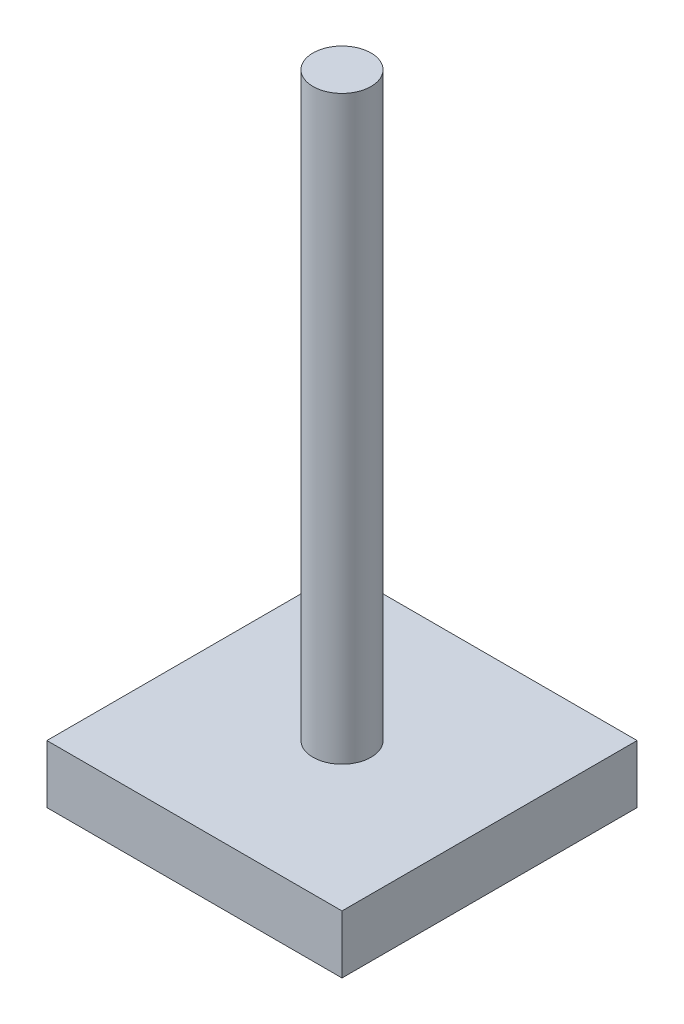
from build123d import *

# Parameters (mm, degrees)
SKETCH2_W           = 50.8
SKETCH2_H           = 50.8
BOSS_EXTRUDE1_DEPTH = 10
SKETCH3_R           = 5
BOSS_EXTRUDE3_DEPTH = 100


with BuildPart() as part:
    # Sketch2 → Boss-Extrude1 (new body)
    with BuildSketch(Plane(origin=(0, 0, 0), x_dir=(1, 0, 0), z_dir=(0, 1, 0))):
        Rectangle(SKETCH2_W, SKETCH2_H)
    extrude(amount=BOSS_EXTRUDE1_DEPTH)

    # Sketch3 → Boss-Extrude3 (add)
    with BuildSketch(Plane(origin=(0, 10, 0), x_dir=(1, 0, 0), z_dir=(0, 1, 0))):
        Circle(SKETCH3_R)
    extrude(amount=BOSS_EXTRUDE3_DEPTH)


solid = part.part
